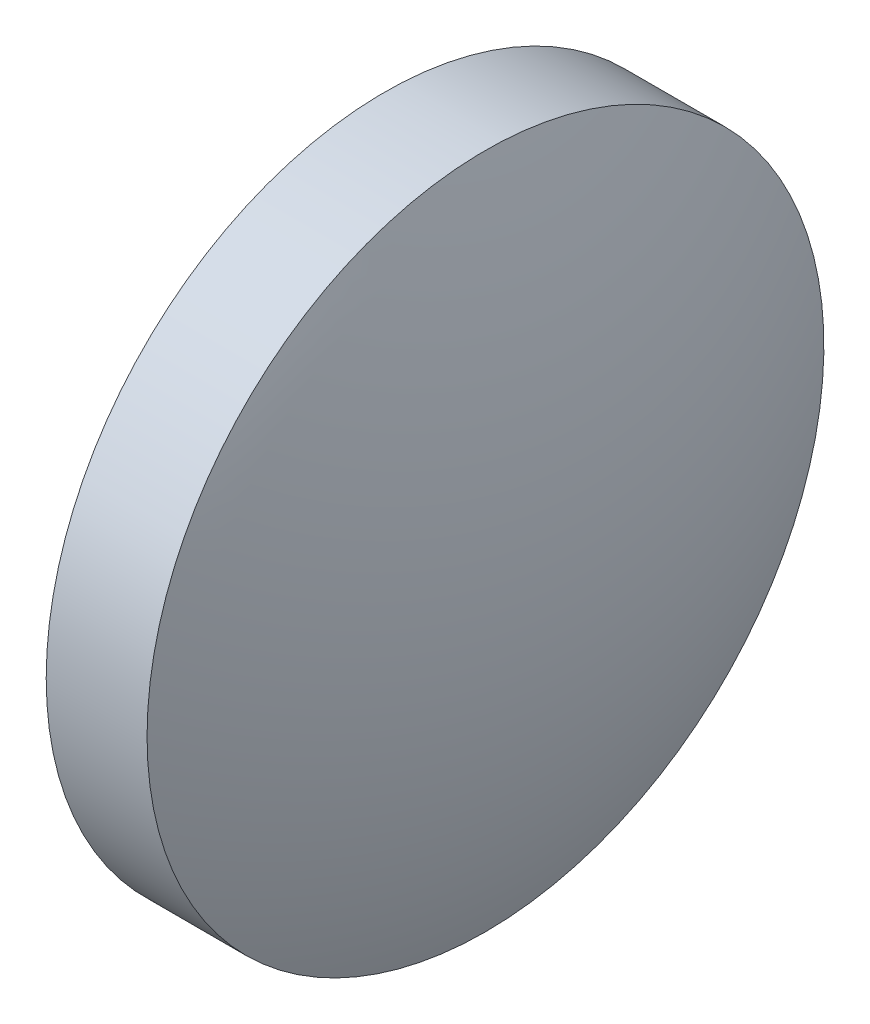
from build123d import *


with BuildPart() as part:
    # 草图1 → 旋转1 (revolve)
    with BuildSketch(Plane.XY, mode=Mode.PRIVATE) as revolve_1_sk:
        with BuildLine():
            Line((662.149854097, 171.216111307), (662.149854097, 176.216111307))
            Line((662.149854097, 176.216111307), (663.639854097, 176.216111307))
            ThreePointArc((663.639854097, 176.216111307), (664.394829592, 173.766606357), (664.649854097, 171.216111307))
            Line((664.649854097, 171.216111307), (662.149854097, 171.216111307))
        make_face()
    revolve(revolve_1_sk.sketch.rotate(Axis((661.352181843, 171.216111307, 0), (1, 0, 0)), 180), axis=Axis((661.352181843, 171.216111307, 0), (1, 0, 0)))  # turned: the seam where the file's is


solid = part.part
